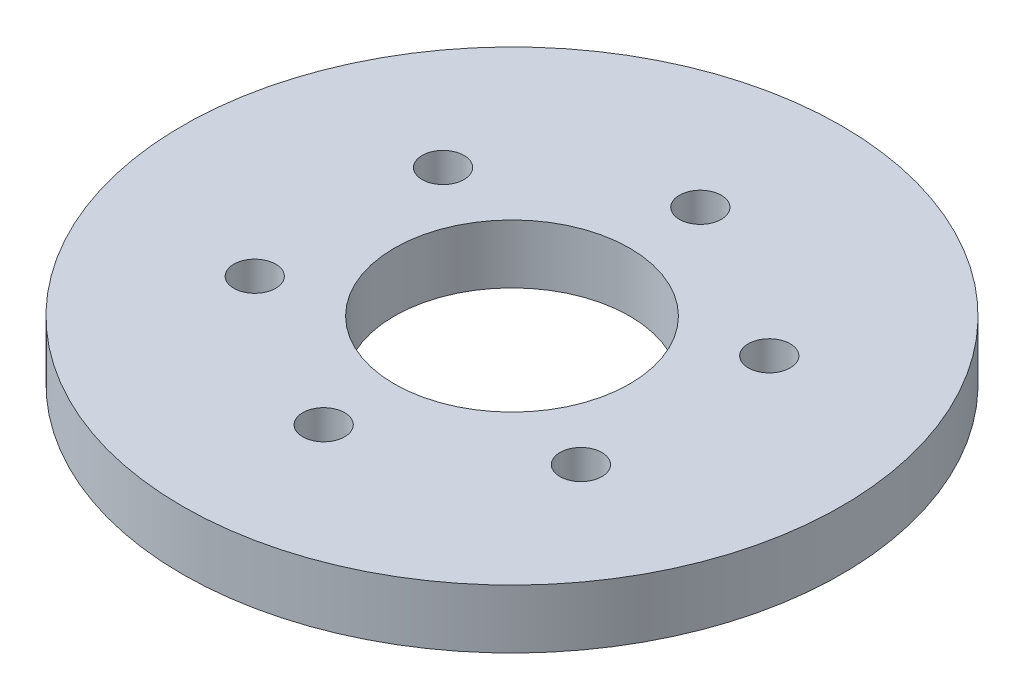
from build123d import *

# Parameters (mm, degrees)
SKETCH1_R                 = 17.78
SKETCH1_R_2               = 6.35
BOSS_EXTRUDE1_DEPTH       = 3.175
TAP_DRILL_FOR_4_40_TAP1_D = 2.2606


with BuildPart() as part:
    # Sketch1 → Boss-Extrude1 (new body)
    with BuildSketch(Plane(origin=(0, 0, 0), x_dir=(1, 0, 0), z_dir=(0, 1, 0))):
        Circle(SKETCH1_R)
        Circle(SKETCH1_R_2, mode=Mode.SUBTRACT)
    extrude(amount=BOSS_EXTRUDE1_DEPTH)

    # Tap Drill for #4-40 Tap1 (through all)
    with Locations(Plane(origin=(0, 0, 0), x_dir=(-1, 0, 0), z_dir=(0, -1, 0))):
        with Locations((0, -10.16), (-8.798818102, -5.08), (-8.798818102, 5.08), (0, 10.16), (8.798818102, 5.08), (8.798818102, -5.08)):
            Hole(TAP_DRILL_FOR_4_40_TAP1_D / 2)


solid = part.part
